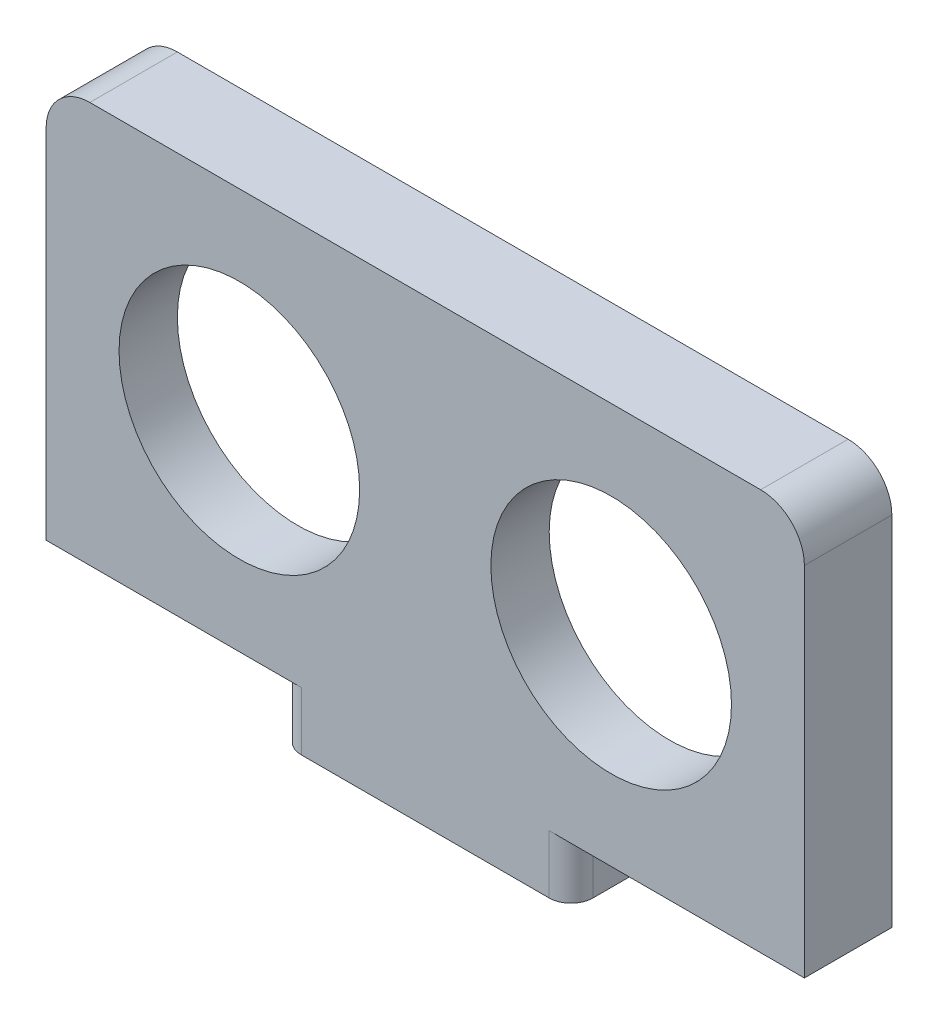
from build123d import *

# Parameters (mm, degrees)
SKETCH_1_W          = 52
SKETCH_1_H          = 27.5
SKETCH_1_R          = 8.25
EXTRUDE_1_DEPTH     = 4
SKETCH_1_3_W        = 52
SKETCH_1_3_H        = 27.5
EXTRUDE_2_DEPTH     = 2
CUT_EXTRUDE_1_DEPTH = 3
FILLET_1_R          = 3
SKETCH_2_W          = 20
SKETCH_2_H          = 6
EXTRUDE_3_DEPTH     = 4
FILLET_2_R          = 1.5


with BuildPart() as part:
    # Эскиз1 → Бобышка-Вытянуть1 (new body)
    with BuildSketch(Plane.XY):
        Rectangle(SKETCH_1_W, SKETCH_1_H)
        with Locations((-12.75, 0)):
            Circle(SKETCH_1_R, mode=Mode.SUBTRACT)
        with Locations((12.75, 0)):
            Circle(SKETCH_1_R, mode=Mode.SUBTRACT)
    extrude(amount=EXTRUDE_1_DEPTH)

    # Эскиз1<3> → Бобышка-Вытянуть2 (add)
    with BuildSketch(Plane.XY):
        Rectangle(SKETCH_1_3_W, SKETCH_1_3_H)
        Polygon((5.5, -10.75), (-5.5, -10.75), (-23, -10.75), (-23, 10.75), (-5.5, 10.75), (5.5, 10.75), (23, 10.75), (23, -10.75), align=None, mode=Mode.SUBTRACT)
    extrude(amount=-EXTRUDE_2_DEPTH)

    # Эскиз1<4> → Вырез-Вытянуть1 (cut)
    with BuildSketch(Plane.XY):
        with BuildLine():
            Line((-5.5, -5.75), (-5.5, -10.75))
            Line((-5.5, -10.75), (5.5, -10.75))
            Line((5.5, -10.75), (5.5, -5.75))
            ThreePointArc((5.5, -5.75), (5.207106781, -5.042893219), (4.5, -4.75))
            Line((4.5, -4.75), (-4.5, -4.75))
            ThreePointArc((-4.5, -4.75), (-5.207106781, -5.042893219), (-5.5, -5.75))
        make_face()
        with BuildLine():
            Line((5.5, 10.75), (-5.5, 10.75))
            Line((-5.5, 10.75), (-5.5, 5.75))
            ThreePointArc((-5.5, 5.75), (-5.207106781, 5.042893219), (-4.5, 4.75))
            Line((-4.5, 4.75), (4.5, 4.75))
            ThreePointArc((4.5, 4.75), (5.207106781, 5.042893219), (5.5, 5.75))
            Line((5.5, 5.75), (5.5, 10.75))
        make_face()
    extrude(amount=CUT_EXTRUDE_1_DEPTH, mode=Mode.SUBTRACT)

    # Скругление1
    fillet_1_edges = [part.edges().sort_by_distance(p)[0] for p in [
        (-26, 13.75, 1),
        (26, 13.75, 1),
    ]]
    fillet(fillet_1_edges, radius=FILLET_1_R)

    # Эскиз2 → Бобышка-Вытянуть3 (add)
    with BuildSketch(Plane.XZ.offset(13.75)):
        with Locations((0, 1)):
            Rectangle(SKETCH_2_W, SKETCH_2_H)
    extrude(amount=EXTRUDE_3_DEPTH)

    # Скругление2
    fillet_2_edges = [part.edges().sort_by_distance(p)[0] for p in [
        (-10, -15.75, -2),
        (-10, -15.75, 4),
        (10, -15.75, -2),
        (10, -15.75, 4),
    ]]
    fillet(fillet_2_edges, radius=FILLET_2_R)


solid = part.part
